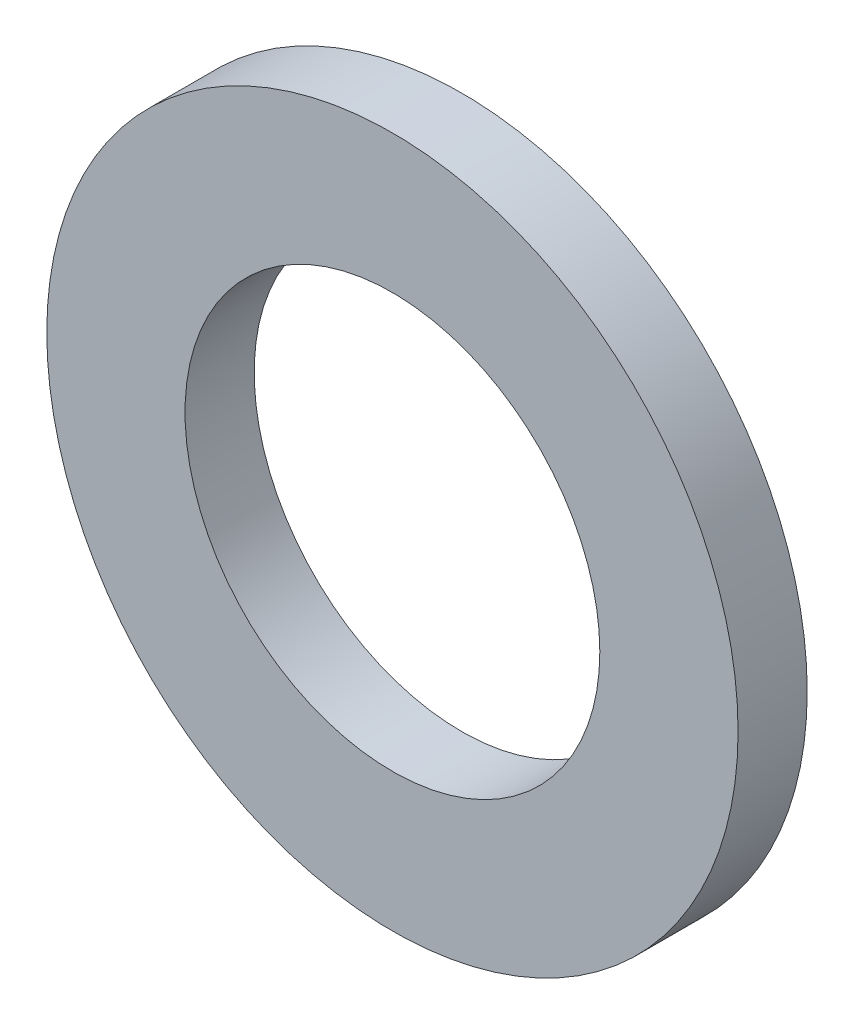
from build123d import *

# Parameters (mm, degrees)
SKETCH_1_R      = 2.5
SKETCH_1_R_2    = 1.5
EXTRUDE_1_DEPTH = 0.5


with BuildPart() as part:
    # 草图1 → 凸台-拉伸1 (new body)
    with BuildSketch(Plane.XY):
        Circle(SKETCH_1_R)
        Circle(SKETCH_1_R_2, mode=Mode.SUBTRACT)
    extrude(amount=EXTRUDE_1_DEPTH)


solid = part.part
